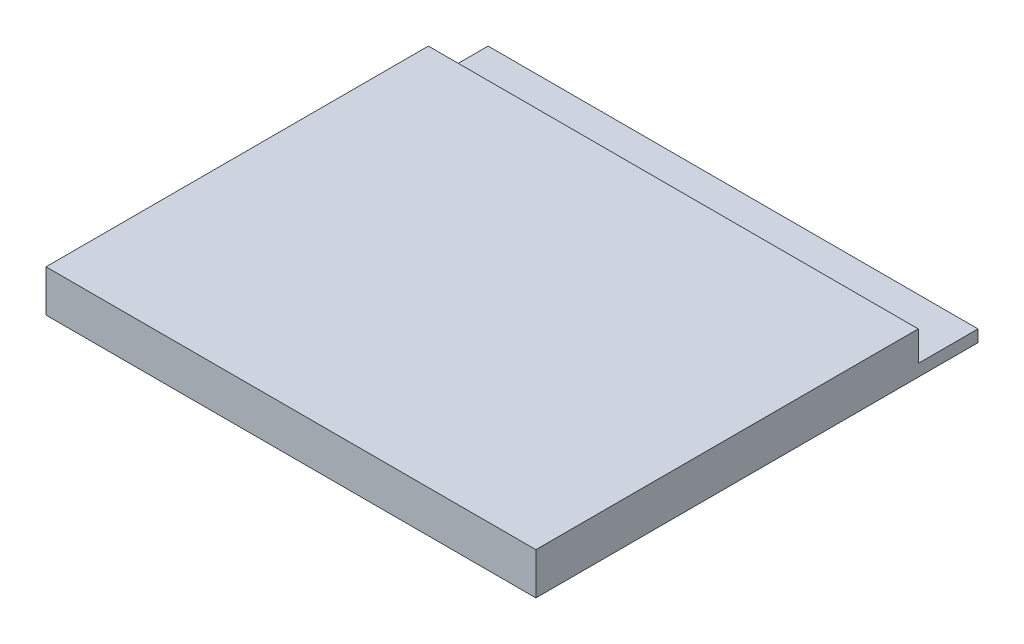
from build123d import *

# Parameters (mm, degrees)
CROQUIS1_W              = 41
CROQUIS1_H              = 32
SALIENTE_EXTRUIR2_DEPTH = 3.5
CROQUIS1_4_W            = 41
CROQUIS1_4_H            = 5
SALIENTE_EXTRUIR3_DEPTH = 1


with BuildPart() as part:
    # Croquis1 → Saliente-Extruir2 (new body)
    with BuildSketch(Plane(origin=(0, 0, 0), x_dir=(1, 0, 0), z_dir=(0, 1, 0))):
        with Locations((20.5, 16)):
            Rectangle(CROQUIS1_W, CROQUIS1_H)
    extrude(amount=SALIENTE_EXTRUIR2_DEPTH)

    # Croquis1_4 → Saliente-Extruir3 (add)
    with BuildSketch(Plane(origin=(0, 0, 0), x_dir=(1, 0, 0), z_dir=(0, 1, 0))):
        with Locations((20.5, 34.5)):
            Rectangle(CROQUIS1_4_W, CROQUIS1_4_H)
    extrude(amount=SALIENTE_EXTRUIR3_DEPTH)


solid = part.part
